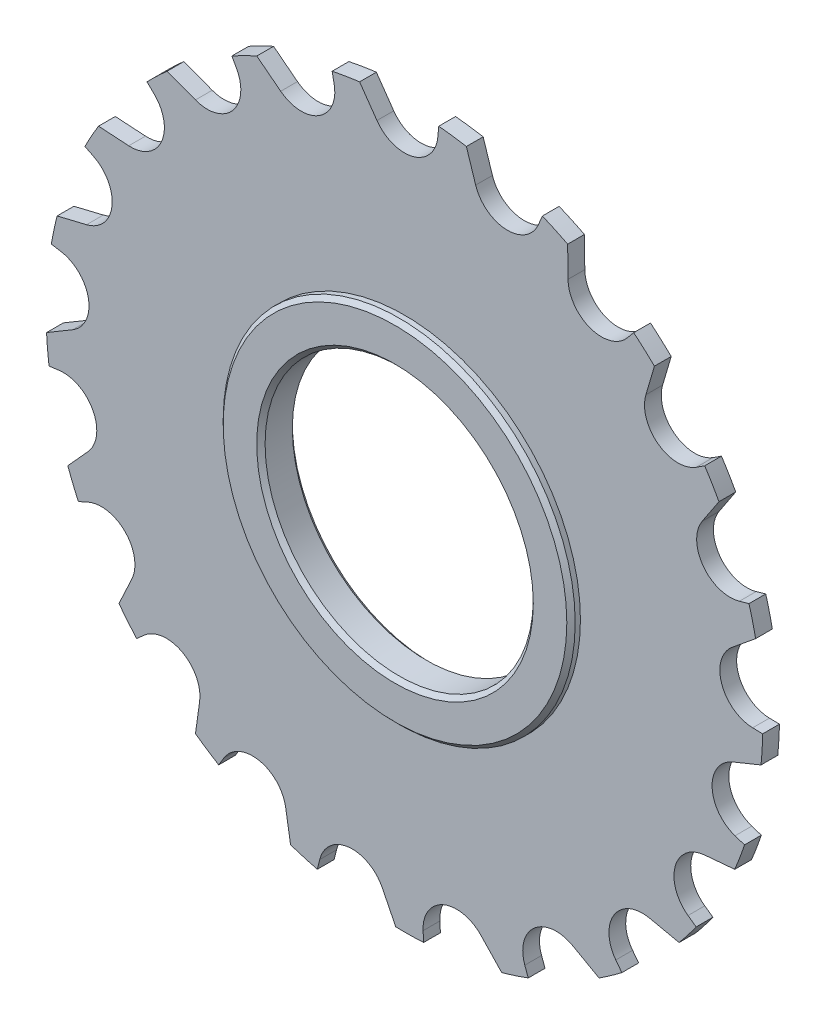
from build123d import *

# Parameters (mm, degrees)
ESQUISSE1_R                  = 42.75
EXTRUSION1_DEPTH             = 1
ENL_V_MAT_EXTRU_1_DEPTH      = 2
R_P_TITION_CIRCULAIRE1_COUNT = 21
ESQUISSE3_R                  = 21
EXTRUSION2_DEPTH             = 2.125
ESQUISSE4_R                  = 16
ENL_V_MAT_EXTRU_2_DEPTH      = 3.125
ENL_V_MAT_EXTRU_2_DEPTH_BACK = 3.125
CHANFREIN1_SIZE              = 0.5


with BuildPart() as part:
    # Esquisse1 → Extrusion1 (new body, symmetric)
    with BuildSketch(Plane.XY):
        Circle(ESQUISSE1_R)
    extrude(amount=EXTRUSION1_DEPTH, both=True)

    # Esquisse2 → Enlèv. mat.-Extru.1 (cut, symmetric)
    with BuildSketch(Plane.XY):
        with BuildLine():
            Line((-5.348139413, 42.414147461), (-3.276608177, 39.455694255))
            ThreePointArc((-3.276608177, 39.455694255), (1.018480402, 37.881835362), (3.981599184, 41.366766467))
            Line((3.981599184, 41.366766467), (4.095808383, 42.553341275))
            ThreePointArc((4.095808383, 42.553341275), (-0.630021414, 42.745357327), (-5.348139413, 42.414147461))
        make_face()
    enl_v_mat_extru_1 = extrude(amount=ENL_V_MAT_EXTRU_1_DEPTH, both=True, mode=Mode.SUBTRACT)

    # Répétition circulaire1: Enlèv. mat.-Extru.1 ×21 about axis
    r_p_tition_circulaire1_axis = Axis((0, 0, 0), (0, 0, 1))
    for i in range(1, R_P_TITION_CIRCULAIRE1_COUNT):
        add(enl_v_mat_extru_1.rotate(r_p_tition_circulaire1_axis, i * 360 / R_P_TITION_CIRCULAIRE1_COUNT), mode=Mode.SUBTRACT)

    # Esquisse3 → Extrusion2 (add, symmetric)
    with BuildSketch(Plane.XY):
        Circle(ESQUISSE3_R)
    extrude(amount=EXTRUSION2_DEPTH, both=True)

    # Esquisse4 → Enlèv. mat.-Extru.2 (cut, two sides)
    with BuildSketch(Plane.XY) as enl_v_mat_extru_2_sk:
        Circle(ESQUISSE4_R)
    extrude(amount=ENL_V_MAT_EXTRU_2_DEPTH, mode=Mode.SUBTRACT)
    extrude(enl_v_mat_extru_2_sk.sketch, amount=-ENL_V_MAT_EXTRU_2_DEPTH_BACK, mode=Mode.SUBTRACT)

    # Chanfrein1
    chanfrein1_edges = [part.edges().sort_by_distance(p)[0] for p in [
        (-21, 0, -2.125),
        (-21, 0, 2.125),
        (-16, 0, -2.125),
        (-16, 0, 2.125),
    ]]
    chamfer(chanfrein1_edges, length=CHANFREIN1_SIZE)


solid = part.part
